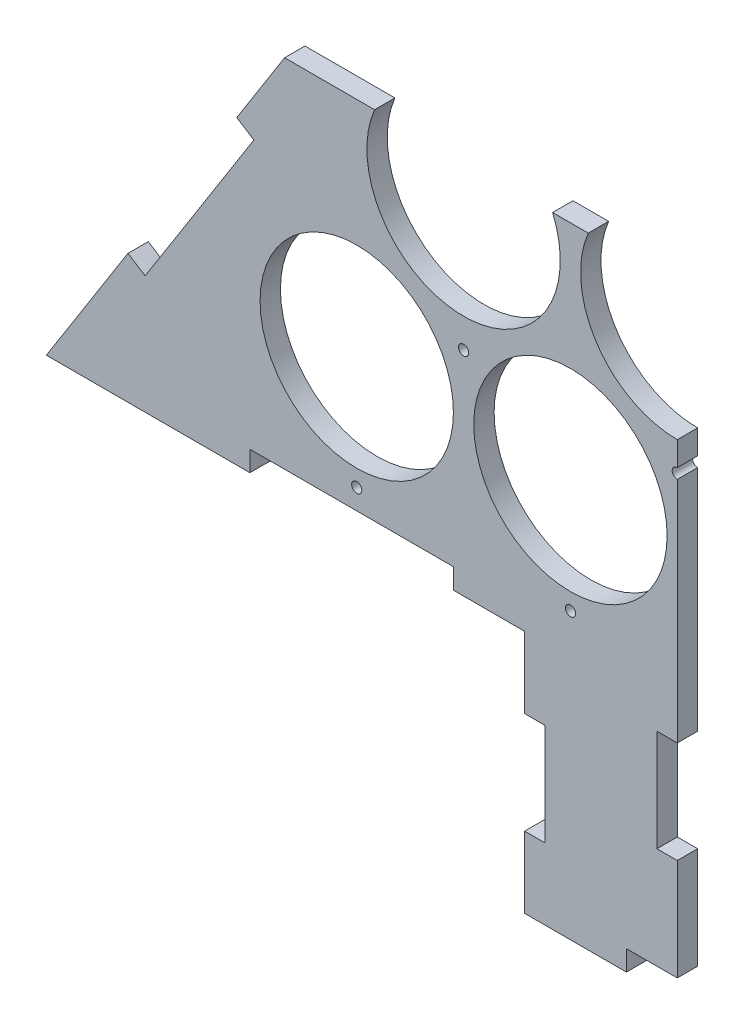
from build123d import *

# Parameters (mm, degrees)
ESQUISSE1_R             = 47.5
BOSS_EXTRU_1_DEPTH      = 10
ESQUISSE3_W             = 100
ESQUISSE3_H             = 10
ENL_V_MAT_EXTRU_1_DEPTH = 11
ESQUISSE4_R             = 2.5
ENL_V_MAT_EXTRU_2_DEPTH = 11
ESQUISSE6_W             = 150
ESQUISSE6_H             = 120
BOSS_EXTRU_2_DEPTH      = 10
ESQUISSE7_W             = 10
ESQUISSE7_H             = 50
ESQUISSE7_W_2           = 50
ESQUISSE7_H_2           = 10
ENL_V_MAT_EXTRU_3_DEPTH = 10
ESQUISSE9_W             = 316.248151929
ESQUISSE9_H             = 610.204039151
ENL_V_MAT_EXTRU_4_DEPTH = 10
ESQUISSE10_W            = 334.898216685
ESQUISSE10_H            = 314.009507296
ENL_V_MAT_EXTRU_6_DEPTH = 10
ESQUISSE11_W            = 10
ESQUISSE11_H            = 50
ENL_V_MAT_EXTRU_7_DEPTH = 10


with BuildPart() as part:
    # Esquisse1 → Boss.-Extru.1 (new body)
    with BuildSketch(Plane.XY):
        Polygon((-310, -75.642859016), (0, 414.561180135), (310, -75.642859016), align=None)
        with Locations((-157.5, 0)):
            Circle(ESQUISSE1_R, mode=Mode.SUBTRACT)
        with Locations((-52.5, 0)):
            Circle(ESQUISSE1_R, mode=Mode.SUBTRACT)
        with Locations((52.5, 0)):
            Circle(ESQUISSE1_R, mode=Mode.SUBTRACT)
        with Locations((157.5, 0)):
            Circle(ESQUISSE1_R, mode=Mode.SUBTRACT)
        with Locations((-105, 90.932667397)):
            Circle(ESQUISSE1_R, mode=Mode.SUBTRACT)
        with Locations((0, 90.932667397)):
            Circle(ESQUISSE1_R, mode=Mode.SUBTRACT)
        with Locations((105, 90.932667397)):
            Circle(ESQUISSE1_R, mode=Mode.SUBTRACT)
        with Locations((-52.5, 181.865334795)):
            Circle(ESQUISSE1_R, mode=Mode.SUBTRACT)
        with Locations((52.5, 181.865334795)):
            Circle(ESQUISSE1_R, mode=Mode.SUBTRACT)
        with Locations((0, 272.798002192)):
            Circle(ESQUISSE1_R, mode=Mode.SUBTRACT)
    extrude(amount=BOSS_EXTRU_1_DEPTH)

    # Esquisse3 → Enlèv. mat.-Extru.1 (cut, through all)
    with BuildSketch(Plane.XY.offset(10)):
        Polygon((-269.913793103, -12.254405678), (-261.461999325, -17.599233264), (-208.013723463, 66.918704521), (-216.465517241, 72.263532107), align=None)
        Polygon((-181.724137931, 127.200191667), (-173.272344153, 121.855364081), (-119.82406829, 206.373301865), (-128.275862069, 211.718129452), align=None)
        Polygon((-93.534482759, 266.654789012), (-85.08268898, 261.309961425), (-31.634413118, 345.82789921), (-40.086206897, 351.172726796), align=None)
        Polygon((269.913793103, -12.254405678), (261.461999325, -17.599233264), (208.013723463, 66.918704521), (216.465517241, 72.263532107), align=None)
        Polygon((181.724137931, 127.200191667), (173.272344153, 121.855364081), (119.82406829, 206.373301865), (128.275862069, 211.718129452), align=None)
        Polygon((93.534482759, 266.654789012), (85.08268898, 261.309961425), (31.634413118, 345.82789921), (40.086206897, 351.172726796), align=None)
        with Locations((-160, -70.642859016)):
            Rectangle(ESQUISSE3_W, ESQUISSE3_H)
        with Locations((160, -70.642859016)):
            Rectangle(ESQUISSE3_W, ESQUISSE3_H)
    extrude(amount=-ENL_V_MAT_EXTRU_1_DEPTH, mode=Mode.SUBTRACT)

    # Esquisse4 → Enlèv. mat.-Extru.2 (cut, through all)
    with BuildSketch(Plane.XY.offset(10)):
        with Locations((-157.5, -55.642859016)):
            Circle(ESQUISSE4_R)
        with Locations((-52.5, -55.642859016)):
            Circle(ESQUISSE4_R)
        with Locations((52.5, -55.642859016)):
            Circle(ESQUISSE4_R)
        with Locations((157.5, -55.642859016)):
            Circle(ESQUISSE4_R)
        with Locations((-105, 29.047375097)):
            Circle(ESQUISSE4_R)
        with Locations((0, 29.047375097)):
            Circle(ESQUISSE4_R)
        with Locations((105, 29.047375097)):
            Circle(ESQUISSE4_R)
        with Locations((-52.5, 119.980042494)):
            Circle(ESQUISSE4_R)
        with Locations((52.5, 119.980042494)):
            Circle(ESQUISSE4_R)
        with Locations((0, 210.912709891)):
            Circle(ESQUISSE4_R)
    extrude(amount=-ENL_V_MAT_EXTRU_2_DEPTH, mode=Mode.SUBTRACT)

    # Esquisse6 → Boss.-Extru.2 (add)
    with BuildSketch(Plane.XY.offset(10)):
        with Locations((0, -135.642859016)):
            Rectangle(ESQUISSE6_W, ESQUISSE6_H)
    extrude(amount=-BOSS_EXTRU_2_DEPTH)

    # Esquisse7 → Enlèv. mat.-Extru.3 (cut)
    with BuildSketch(Plane.XY.offset(10)):
        with Locations((-70, -135.642859016)):
            Rectangle(ESQUISSE7_W, ESQUISSE7_H)
        with Locations((0, -190.642859016)):
            Rectangle(ESQUISSE7_W_2, ESQUISSE7_H_2)
        with Locations((70, -135.642859016)):
            Rectangle(ESQUISSE7_W, ESQUISSE7_H)
    extrude(amount=-ENL_V_MAT_EXTRU_3_DEPTH, mode=Mode.SUBTRACT)

    # Esquisse9 → Enlèv. mat.-Extru.4 (cut)
    with BuildSketch(Plane.XY.offset(10)):
        with Locations((158.124075965, 109.45916056)):
            Rectangle(ESQUISSE9_W, ESQUISSE9_H)
    extrude(amount=-ENL_V_MAT_EXTRU_4_DEPTH, mode=Mode.SUBTRACT)

    # Esquisse10 → Enlèv. mat.-Extru.6 (cut)
    with BuildSketch(Plane.XY.offset(10)):
        with Locations((-167.449108343, 266.465933783)):
            Rectangle(ESQUISSE10_W, ESQUISSE10_H)
    extrude(amount=-ENL_V_MAT_EXTRU_6_DEPTH, mode=Mode.SUBTRACT)

    # Esquisse11 → Enlèv. mat.-Extru.7 (cut)
    with BuildSketch(Plane.XY.offset(10)):
        with Locations((-5, -110.642859016)):
            Rectangle(ESQUISSE11_W, ESQUISSE11_H)
    extrude(amount=-ENL_V_MAT_EXTRU_7_DEPTH, mode=Mode.SUBTRACT)


solid = part.part
